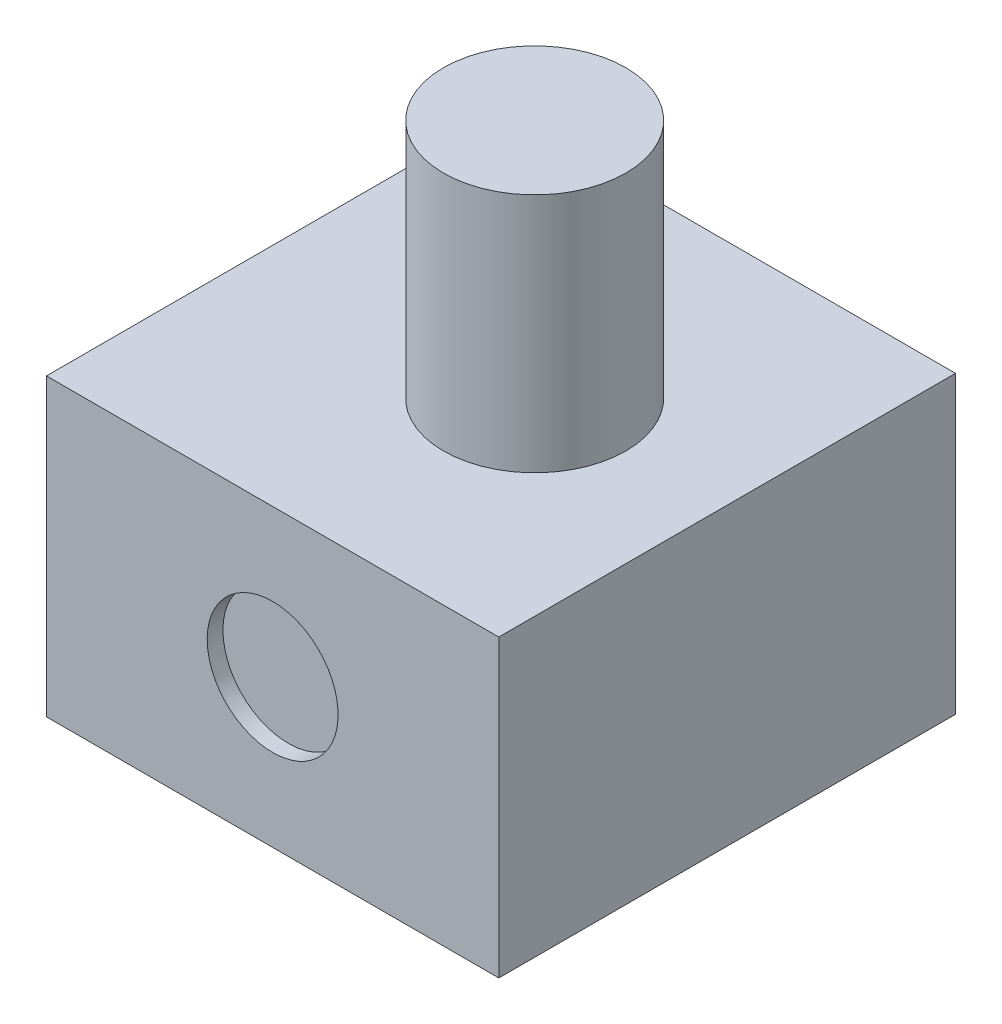
from build123d import *

# Parameters (mm, degrees)
SKETCH1_W           = 73.025
SKETCH1_H           = 73.7362
BOSS_EXTRUDE1_DEPTH = 47.6758
SKETCH2_R           = 10.5664
CUT_EXTRUDE1_DEPTH  = 2.54
SKETCH3_R           = 14.732
BOSS_EXTRUDE2_DEPTH = 38.862


with BuildPart() as part:
    # Sketch1 → Boss-Extrude1 (new body)
    with BuildSketch(Plane(origin=(0, 0, 0), x_dir=(1, 0, 0), z_dir=(0, 1, 0))):
        with Locations((36.5125, -36.8681)):
            Rectangle(SKETCH1_W, SKETCH1_H)
    extrude(amount=BOSS_EXTRUDE1_DEPTH)

    # Sketch2 → Cut-Extrude1 (cut)
    with BuildSketch(Plane(origin=(0, 0, 0), x_dir=(-1, 0, 0), z_dir=(0, 0, -1))):
        with Locations((-36.5125, 23.8379)):
            Circle(SKETCH2_R)
    cut_extrude1 = extrude(amount=-CUT_EXTRUDE1_DEPTH, mode=Mode.SUBTRACT)

    # Sketch3 → Boss-Extrude2 (add)
    with BuildSketch(Plane(origin=(0, 47.6758, 0), x_dir=(1, 0, 0), z_dir=(0, 1, 0))):
        with Locations((42.545, -37.465)):
            Circle(SKETCH3_R)
    extrude(amount=BOSS_EXTRUDE2_DEPTH)

    # Mirror1: Cut-Extrude1 across plane
    add(cut_extrude1.mirror(Plane.XY.offset(36.8681)), mode=Mode.SUBTRACT)


solid = part.part
